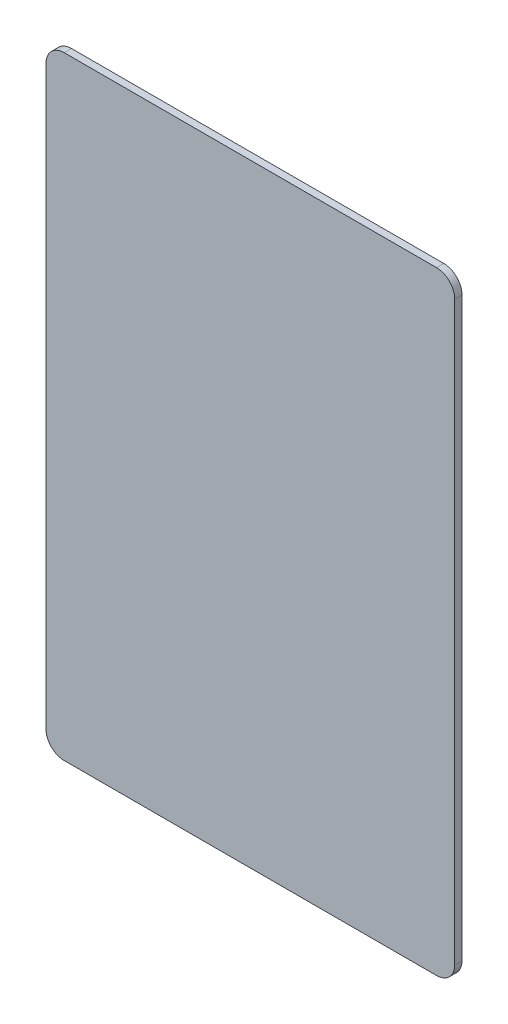
from build123d import *

# Parameters (mm, degrees)
BOSS_EXTRU_1_DEPTH = 1.6


with BuildPart() as part:
    # Esquisse1 → Boss.-Extru.1 (new body)
    with BuildSketch(Plane.XY):
        with BuildLine():
            Line((4, 0), (86, 0))
            ThreePointArc((86, 0), (88.828427125, -1.171572875), (90, -4))
            Line((90, -4), (90, -131))
            ThreePointArc((90, -131), (88.828427125, -133.828427125), (86, -135))
            Line((86, -135), (4, -135))
            ThreePointArc((4, -135), (1.171572875, -133.828427125), (0, -131))
            Line((0, -131), (0, -4))
            ThreePointArc((0, -4), (1.171572875, -1.171572875), (4, 0))
        make_face()
    extrude(amount=BOSS_EXTRU_1_DEPTH)


solid = part.part
